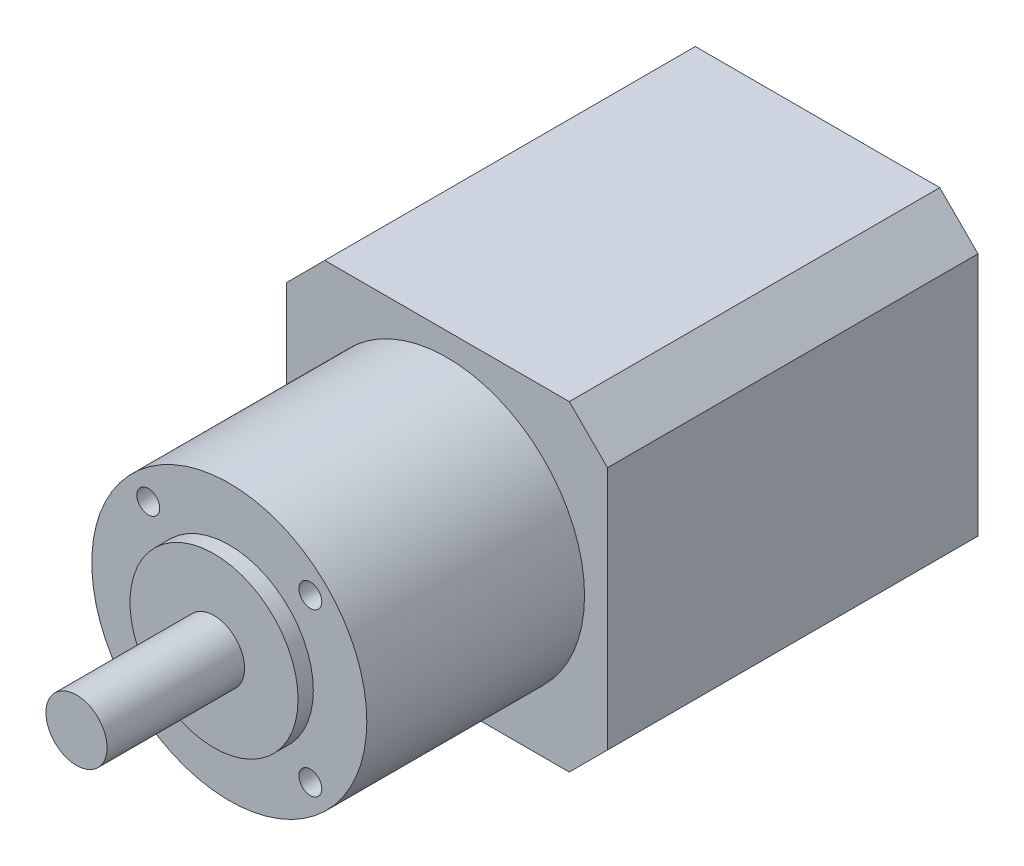
from build123d import *

# Parameters (mm, degrees)
SKETCH1_W           = 42
SKETCH1_H           = 42
BOSS_EXTRUDE1_DEPTH = 48.5
SKETCH2_R           = 18
BOSS_EXTRUDE2_DEPTH = 28.5
SKETCH3_R           = 11
SKETCH3_R_2         = 4
BOSS_EXTRUDE3_DEPTH = 2
SKETCH3_2_R         = 4
BOSS_EXTRUDE4_DEPTH = 20
SKETCH4_R           = 1.5
CUT_EXTRUDE1_DEPTH  = 10
CHAMFER1_SIZE       = 5


with BuildPart() as part:
    # Sketch1 → Boss-Extrude1 (new body)
    with BuildSketch(Plane.XY):
        Rectangle(SKETCH1_W, SKETCH1_H)
    extrude(amount=BOSS_EXTRUDE1_DEPTH)

    # Sketch2 → Boss-Extrude2 (add)
    with BuildSketch(Plane.XY.offset(48.5)):
        Circle(SKETCH2_R)
    extrude(amount=BOSS_EXTRUDE2_DEPTH)

    # Sketch3 → Boss-Extrude3 (add)
    with BuildSketch(Plane.XY.offset(77)):
        Circle(SKETCH3_R)
        Circle(SKETCH3_R_2, mode=Mode.SUBTRACT)
    extrude(amount=BOSS_EXTRUDE3_DEPTH)

    # Sketch3_2 → Boss-Extrude4 (add)
    with BuildSketch(Plane.XY.offset(77)):
        Circle(SKETCH3_2_R)
    extrude(amount=BOSS_EXTRUDE4_DEPTH)

    # Sketch4 → Cut-Extrude1 (cut)
    with BuildSketch(Plane.XY.offset(77)):
        with Locations((10.606601718, -10.606601718)):
            Circle(SKETCH4_R)
        with Locations((-10.606601718, -10.606601718)):
            Circle(SKETCH4_R)
        with Locations((-10.606601718, 10.606601718)):
            Circle(SKETCH4_R)
        with Locations((10.606601718, 10.606601718)):
            Circle(SKETCH4_R)
    extrude(amount=-CUT_EXTRUDE1_DEPTH, mode=Mode.SUBTRACT)

    # Chamfer1
    chamfer1_edges = [part.edges().sort_by_distance(p)[0] for p in [
        (21, -21, 24.25),
        (21, 21, 24.25),
        (-21, 21, 24.25),
        (-21, -21, 24.25),
    ]]
    chamfer(chamfer1_edges, length=CHAMFER1_SIZE)


solid = part.part
